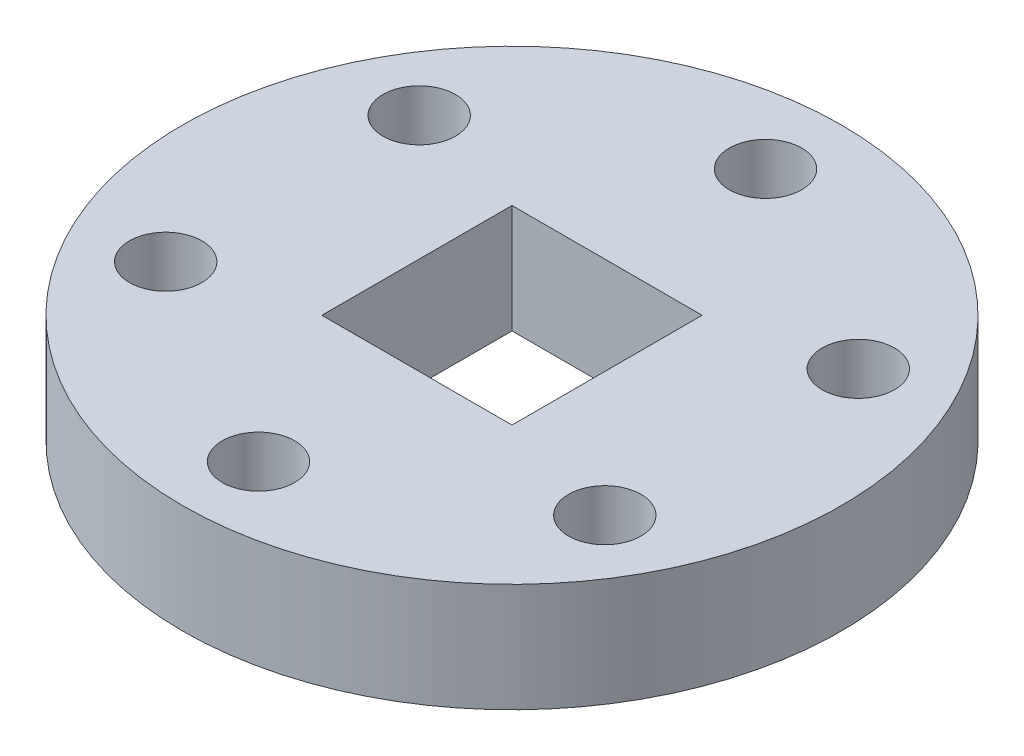
from build123d import *

# Parameters (mm, degrees)
SKETCH1_R           = 18.2
BOSS_EXTRUDE1_DEPTH = 6
SKETCH2_R           = 2
CUT_EXTRUDE1_DEPTH  = 6
SKETCH3_W           = 10.5
SKETCH3_H           = 10.5
CUT_EXTRUDE2_DEPTH  = 6


with BuildPart() as part:
    # Sketch1 → Boss-Extrude1 (new body)
    with BuildSketch(Plane(origin=(0, 0, 0), x_dir=(1, 0, 0), z_dir=(0, 1, 0))):
        Circle(SKETCH1_R)
    extrude(amount=BOSS_EXTRUDE1_DEPTH)

    # Sketch2 → Cut-Extrude1 (cut)
    with BuildSketch(Plane(origin=(0, 6, 0), x_dir=(1, 0, 0), z_dir=(0, 1, 0))):
        with Locations((0, 14)):
            Circle(SKETCH2_R)
        with Locations((12.124355653, 7)):
            Circle(SKETCH2_R)
        with Locations((12.124355653, -7)):
            Circle(SKETCH2_R)
        with Locations((0, -14)):
            Circle(SKETCH2_R)
        with Locations((-12.124355653, -7)):
            Circle(SKETCH2_R)
        with Locations((-12.124355653, 7)):
            Circle(SKETCH2_R)
    extrude(amount=-CUT_EXTRUDE1_DEPTH, mode=Mode.SUBTRACT)

    # Sketch3 → Cut-Extrude2 (cut)
    with BuildSketch(Plane(origin=(0, 6, 0), x_dir=(1, 0, 0), z_dir=(0, 1, 0))):
        Rectangle(SKETCH3_W, SKETCH3_H)
    extrude(amount=-CUT_EXTRUDE2_DEPTH, mode=Mode.SUBTRACT)


solid = part.part
